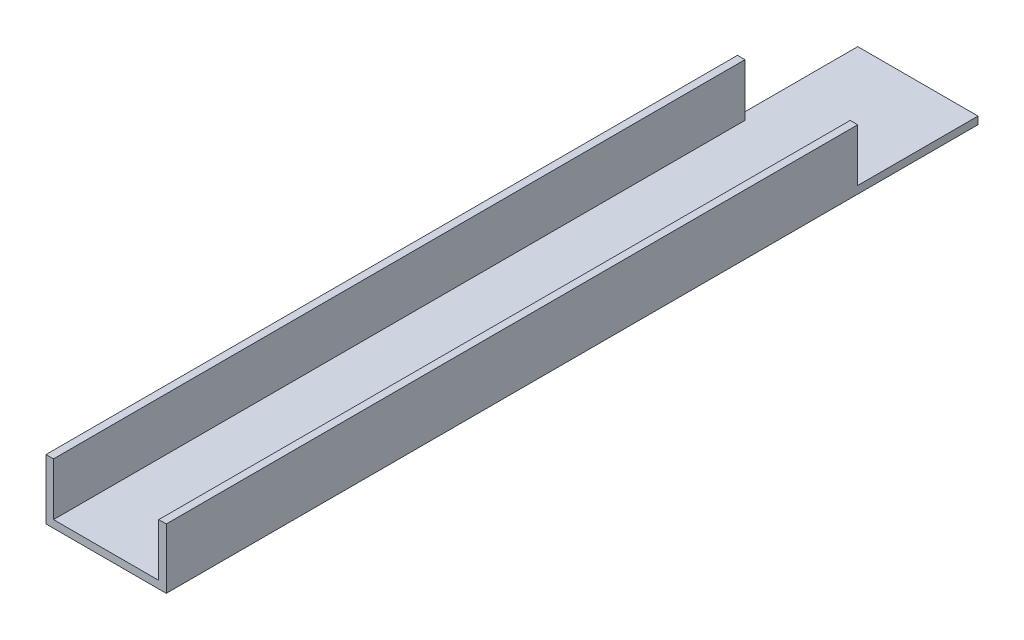
from build123d import *

# Parameters (mm, degrees)
BOSS_EXTRUDE1_DEPTH = 342.9
SKETCH2_W           = 50.8
SKETCH2_H           = 50.8
CUT_EXTRUDE1_DEPTH  = 22.225


with BuildPart() as part:
    # Sketch1 → Boss-Extrude1 (new body)
    with BuildSketch(Plane.XY):
        Polygon((3.175, 3.175), (3.175, 25.4), (0, 25.4), (0, 0), (50.8, 0), (50.8, 25.4), (47.625, 25.4), (47.625, 3.175), align=None)
    extrude(amount=BOSS_EXTRUDE1_DEPTH)

    # Sketch2 → Cut-Extrude1 (cut)
    with BuildSketch(Plane(origin=(0, 25.4, 0), x_dir=(1, 0, 0), z_dir=(0, 1, 0))):
        with Locations((25.4, -25.4)):
            Rectangle(SKETCH2_W, SKETCH2_H)
    extrude(amount=-CUT_EXTRUDE1_DEPTH, mode=Mode.SUBTRACT)


solid = part.part
